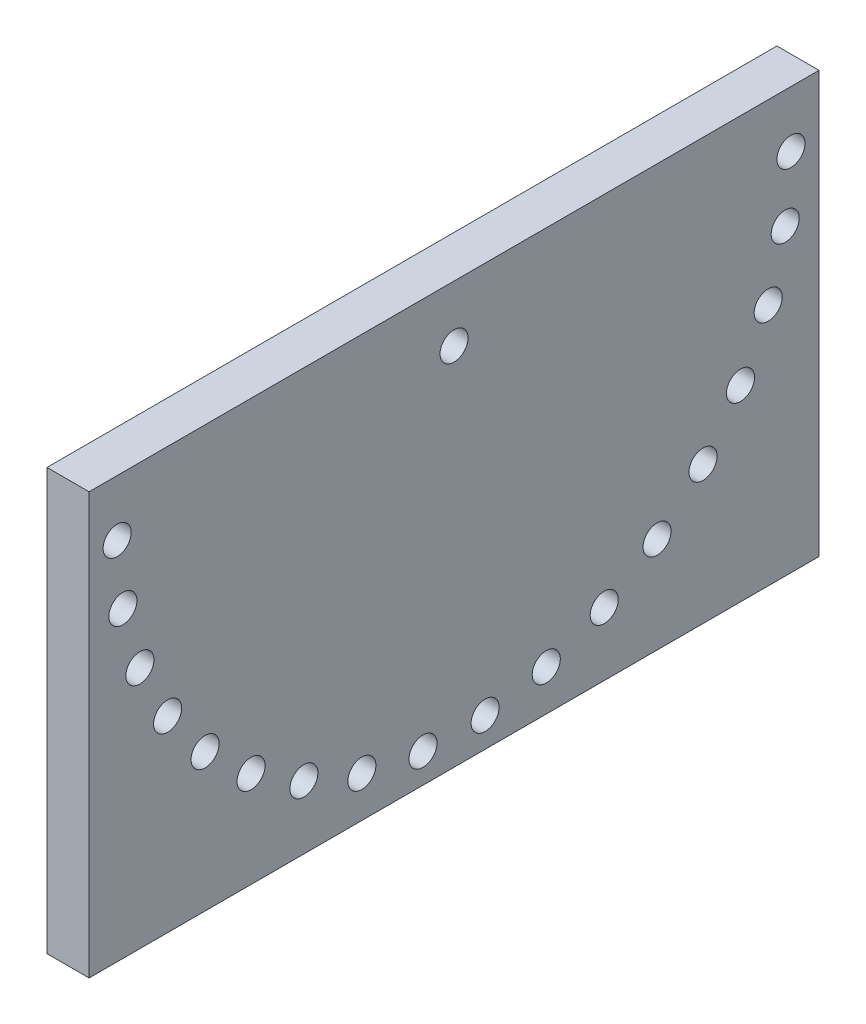
from build123d import *

# Parameters (mm, degrees)
SKETCH1_W           = 260
SKETCH1_H           = 150
BOSS_EXTRUDE1_DEPTH = 15
SKETCH3_R           = 5
CUT_EXTRUDE1_DEPTH  = 16
SKETCH4_R           = 5
CUT_EXTRUDE2_DEPTH  = 16


with BuildPart() as part:
    # Sketch1 → Boss-Extrude1 (new body)
    with BuildSketch(Plane(origin=(0, 0, 0), x_dir=(0, 0, -1), z_dir=(1, 0, 0))):
        Rectangle(SKETCH1_W, SKETCH1_H)
    extrude(amount=BOSS_EXTRUDE1_DEPTH)

    # Sketch3 → Cut-Extrude1 (cut, through all)
    with BuildSketch(Plane.ZY):
        with Locations((0, 55)):
            Circle(SKETCH3_R)
    extrude(amount=-CUT_EXTRUDE1_DEPTH, mode=Mode.SUBTRACT)

    # Sketch4 → Cut-Extrude2 (cut, through all)
    with BuildSketch(Plane.ZY):
        with Locations((-120, 55)):
            Circle(SKETCH4_R)
        with Locations((-117.956771962, 32.950057862)):
            Circle(SKETCH4_R)
        with Locations((-111.896667529, 11.651000058)):
            Circle(SKETCH4_R)
        with Locations((-102.026056288, -8.171859545)):
            Circle(SKETCH4_R)
        with Locations((-88.681070066, -25.843477238)):
            Circle(SKETCH4_R)
        with Locations((-72.316156366, -40.762067274)):
            Circle(SKETCH4_R)
        with Locations((-53.488602693, -52.419594963)):
            Circle(SKETCH4_R)
        with Locations((-32.839558809, -60.419077181)):
            Circle(SKETCH4_R)
        with Locations((-11.072203136, -64.488101155)):
            Circle(SKETCH4_R)
        with Locations((11.072203136, -64.488101155)):
            Circle(SKETCH4_R)
        with Locations((32.839558809, -60.419077181)):
            Circle(SKETCH4_R)
        with Locations((53.488602693, -52.419594963)):
            Circle(SKETCH4_R)
        with Locations((72.316156366, -40.762067274)):
            Circle(SKETCH4_R)
        with Locations((88.681070066, -25.843477238)):
            Circle(SKETCH4_R)
        with Locations((102.026056288, -8.171859545)):
            Circle(SKETCH4_R)
        with Locations((111.896667529, 11.651000058)):
            Circle(SKETCH4_R)
        with Locations((117.956771962, 32.950057862)):
            Circle(SKETCH4_R)
        with Locations((120, 55)):
            Circle(SKETCH4_R)
    extrude(amount=-CUT_EXTRUDE2_DEPTH, mode=Mode.SUBTRACT)


solid = part.part
